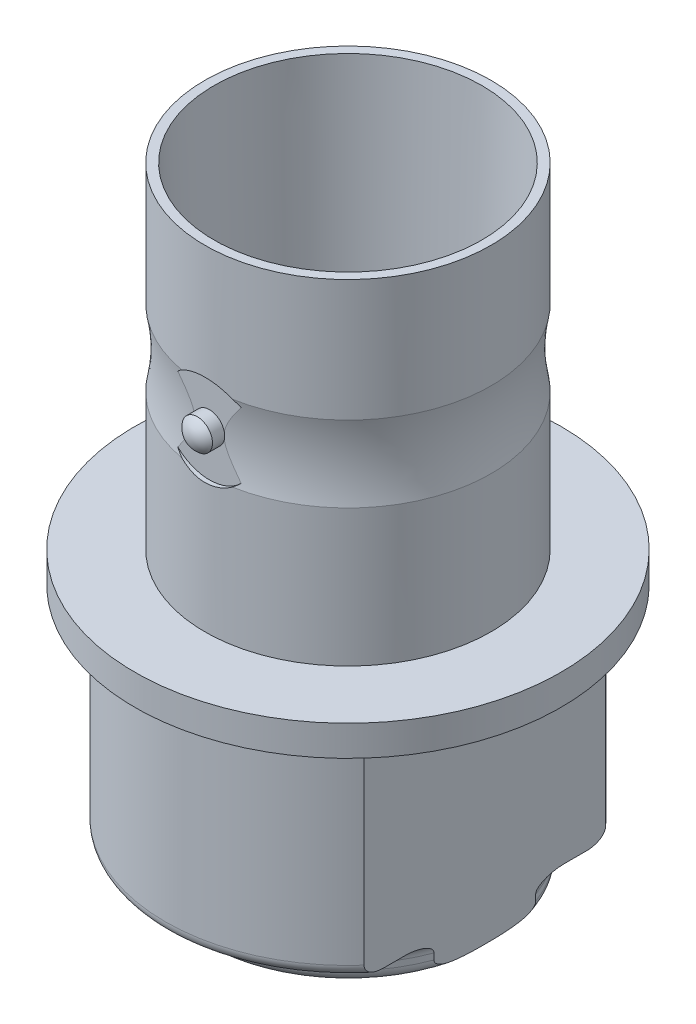
from build123d import *

# Parameters (mm, degrees)
SKETCH_2_W                            = 2.5
SKETCH_2_H                            = 8
CUT_EXTRUDE_1_DEPTH                   = 10
SKETCH_5_R                            = 1.5
CUT_EXTRUDE_4_DEPTH                   = 0.15
SKETCH_7_R                            = 0.5
EXTRUDE_1_DEPTH                       = 0.4
DOME_1_FACE_RADIUS                    = 0.5
DOME_1_HEIGHT                         = 0.25
PATTERN_CIRCULAR_1_COUNT              = 2
PATTERN_CIRCULAR_1_COPY_1_FACE_RADIUS = 0.5
PATTERN_CIRCULAR_1_COPY_1_HEIGHT      = 0.25


with BuildPart() as part:
    # Sketch 1 → Revolve 1 (revolve)
    with BuildSketch(Plane(origin=(0, 0, 0), x_dir=(0, 0, -1), z_dir=(1, 0, 0))):
        with BuildLine():
            Line((4.7, 20), (4.7, 16))
            ThreePointArc((4.7, 16), (4.57524704, 14.75), (4.7, 13.5))
            Line((4.7, 13.5), (4.7, 9))
            Line((4.7, 9), (7, 9))
            Line((7, 9), (7, 8))
            Line((7, 8), (6, 8))
            Line((6, 8), (6, 1.4))
            ThreePointArc((6, 1.4), (5.882842712, 1.117157288), (5.6, 1))
            Line((5.6, 1), (5.2, 1))
            ThreePointArc((5.2, 1), (4.917157288, 0.882842712), (4.8, 0.6))
            Line((4.8, 0.6), (4.8, 0.4))
            ThreePointArc((4.8, 0.4), (4.682842712, 0.117157288), (4.4, 0))
            Line((4.4, 0), (3, 0))
            Line((3, 0), (3, 8))
            Line((3, 8), (4, 8))
            Line((4, 8), (4.4, 20))
            Line((4.4, 20), (4.7, 20))
        make_face()
    revolve(axis=Axis((0, 0, 0), (0, 1, 0)))

    # Sketch 2 → Cut-Extrude 1 (cut, symmetric)
    with BuildSketch(Plane.XY):
        with Locations((-5.75, 4)):
            Rectangle(SKETCH_2_W, SKETCH_2_H)
        with Locations((5.75, 4)):
            Rectangle(SKETCH_2_W, SKETCH_2_H)
    extrude(amount=CUT_EXTRUDE_1_DEPTH, both=True, mode=Mode.SUBTRACT)

    # Sketch 5 → Cut-Extrude 4 (cut)
    with BuildSketch(Plane.XY.offset(4.7)):
        with Locations((0, 14.75)):
            Circle(SKETCH_5_R)
    cut_extrude_4 = extrude(amount=-CUT_EXTRUDE_4_DEPTH, mode=Mode.SUBTRACT)

    # Sketch 7 → Extrude 1 (add)
    with BuildSketch(Plane.XY.offset(4.55)):
        with Locations(Location((0, 14.75, 0), (0, 0, 192.319298658))):
            Circle(SKETCH_7_R)
    extrude_1 = extrude(amount=EXTRUDE_1_DEPTH)

    # Dome 1: a dome of height H over a round flat face of radius A is a cap of a sphere of radius (A * A + H * H) / (2 * H)
    dome_1_r = (DOME_1_FACE_RADIUS * DOME_1_FACE_RADIUS + DOME_1_HEIGHT * DOME_1_HEIGHT) / (2 * DOME_1_HEIGHT)
    dome_1_base = Plane((0, 14.75, 4.95), z_dir=(0, 0, 1))
    with Locations(dome_1_base.offset(DOME_1_HEIGHT - dome_1_r)):
        dome_1_ball = Sphere(dome_1_r, mode=Mode.PRIVATE)
    add(split(dome_1_ball, bisect_by=dome_1_base, keep=Keep.TOP, mode=Mode.PRIVATE))

    # Pattern Circular 1: Cut-Extrude 4, Extrude 1 ×2 about axis
    pattern_circular_1_axis = Axis((0, 9, 0), (0, -1, 0))
    add([cut_extrude_4.rotate(pattern_circular_1_axis, i * 360 / PATTERN_CIRCULAR_1_COUNT) for i in range(1, PATTERN_CIRCULAR_1_COUNT)], mode=Mode.SUBTRACT)
    add([extrude_1.rotate(pattern_circular_1_axis, i * 360 / PATTERN_CIRCULAR_1_COUNT) for i in range(1, PATTERN_CIRCULAR_1_COUNT)])

    # Pattern Circular 1 copy 1: a dome of height H over a round flat face of radius A is a cap of a sphere of radius (A * A + H * H) / (2 * H)
    pattern_circular_1_copy_1_r = (PATTERN_CIRCULAR_1_COPY_1_FACE_RADIUS * PATTERN_CIRCULAR_1_COPY_1_FACE_RADIUS + PATTERN_CIRCULAR_1_COPY_1_HEIGHT * PATTERN_CIRCULAR_1_COPY_1_HEIGHT) / (2 * PATTERN_CIRCULAR_1_COPY_1_HEIGHT)
    pattern_circular_1_copy_1_base = Plane((0, 14.75, -4.95), z_dir=(0, 0, -1))
    with Locations(pattern_circular_1_copy_1_base.offset(PATTERN_CIRCULAR_1_COPY_1_HEIGHT - pattern_circular_1_copy_1_r)):
        pattern_circular_1_copy_1_ball = Sphere(pattern_circular_1_copy_1_r, mode=Mode.PRIVATE)
    add(split(pattern_circular_1_copy_1_ball, bisect_by=pattern_circular_1_copy_1_base, keep=Keep.TOP, mode=Mode.PRIVATE))


solid = part.part
